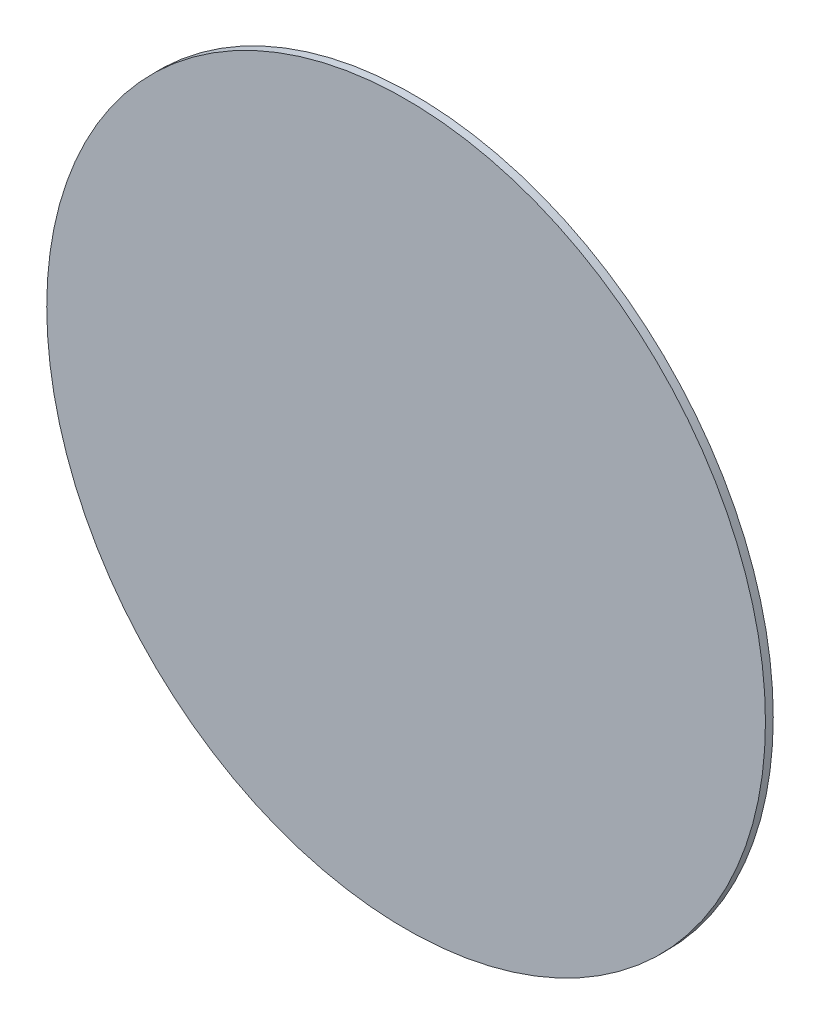
from build123d import *

# Parameters (mm, degrees)
SKETCH1_R           = 46
BOSS_EXTRUDE1_DEPTH = 1


with BuildPart() as part:
    # Sketch1 → Boss-Extrude1 (new body)
    with BuildSketch(Plane.XY):
        Circle(SKETCH1_R)
    extrude(amount=BOSS_EXTRUDE1_DEPTH)


solid = part.part
